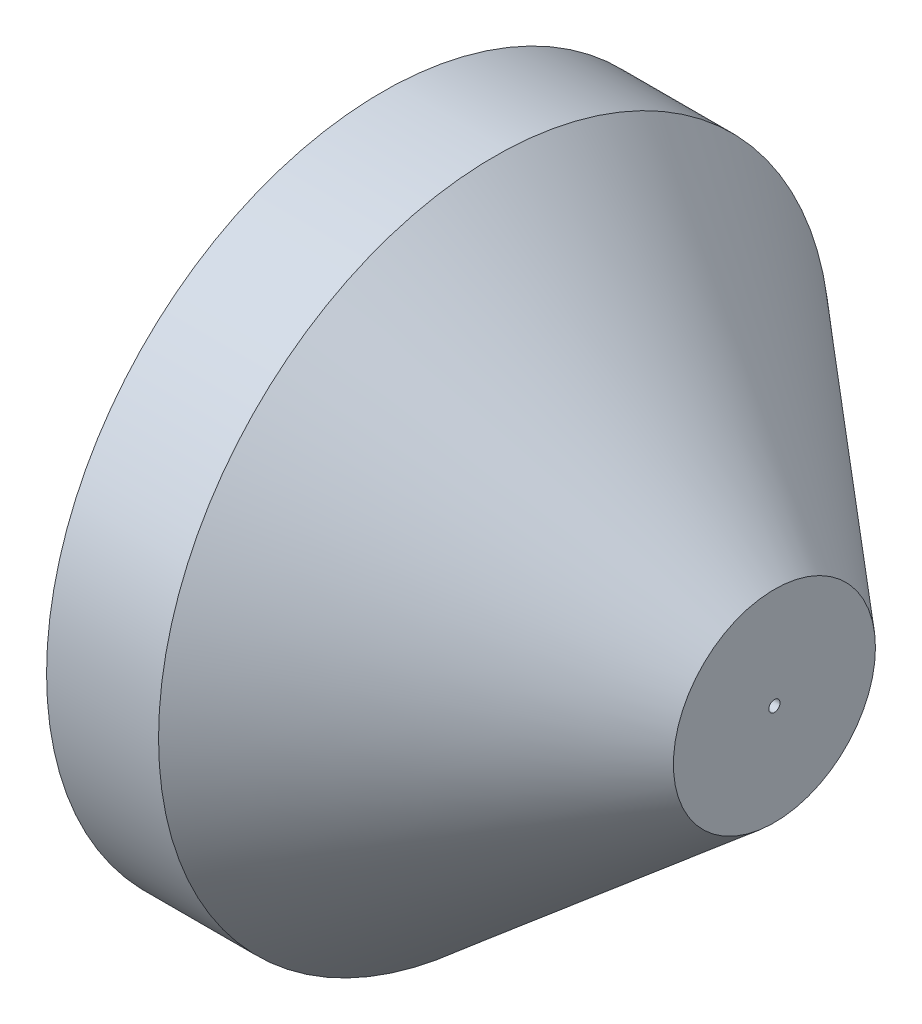
from build123d import *

# Parameters (mm, degrees)
SKETCH1_R           = 50
SKETCH1_R_2         = 30
BOSS_EXTRUDE1_DEPTH = 20
SKETCH2_R           = 60
BOSS_EXTRUDE4_DEPTH = 50
BOSS_EXTRUDE4_TAPER = 40
SKETCH5_R           = 60
SKETCH5_R_2         = 55
BOSS_EXTRUDE5_DEPTH = 20
SKETCH6_R           = 1
CUT_EXTRUDE1_DEPTH  = 51.0000001


with BuildPart() as part:
    # Sketch1 → Boss-Extrude1 (new body)
    with BuildSketch(Plane(origin=(0, 0, 0), x_dir=(0, 0, -1), z_dir=(1, 0, 0))):
        Circle(SKETCH1_R)
        Circle(SKETCH1_R_2, mode=Mode.SUBTRACT)
    extrude(amount=BOSS_EXTRUDE1_DEPTH)

    # Sketch2 → Boss-Extrude4 (add)
    with BuildSketch(Plane(origin=(20, 0, 0), x_dir=(0, 0, -1), z_dir=(1, 0, 0))):
        Circle(SKETCH2_R)
    extrude(amount=BOSS_EXTRUDE4_DEPTH, taper=BOSS_EXTRUDE4_TAPER)

    # Sketch5 → Boss-Extrude5 (add)
    with BuildSketch(Plane.ZY.offset(-20)):
        Circle(SKETCH5_R)
        Circle(SKETCH5_R_2, mode=Mode.SUBTRACT)
    extrude(amount=BOSS_EXTRUDE5_DEPTH)

    # Sketch6 → Cut-Extrude1 (cut, through all)
    with BuildSketch(Plane.ZY.offset(-20)):
        Circle(SKETCH6_R)
    extrude(amount=-CUT_EXTRUDE1_DEPTH, mode=Mode.SUBTRACT)


solid = part.part
